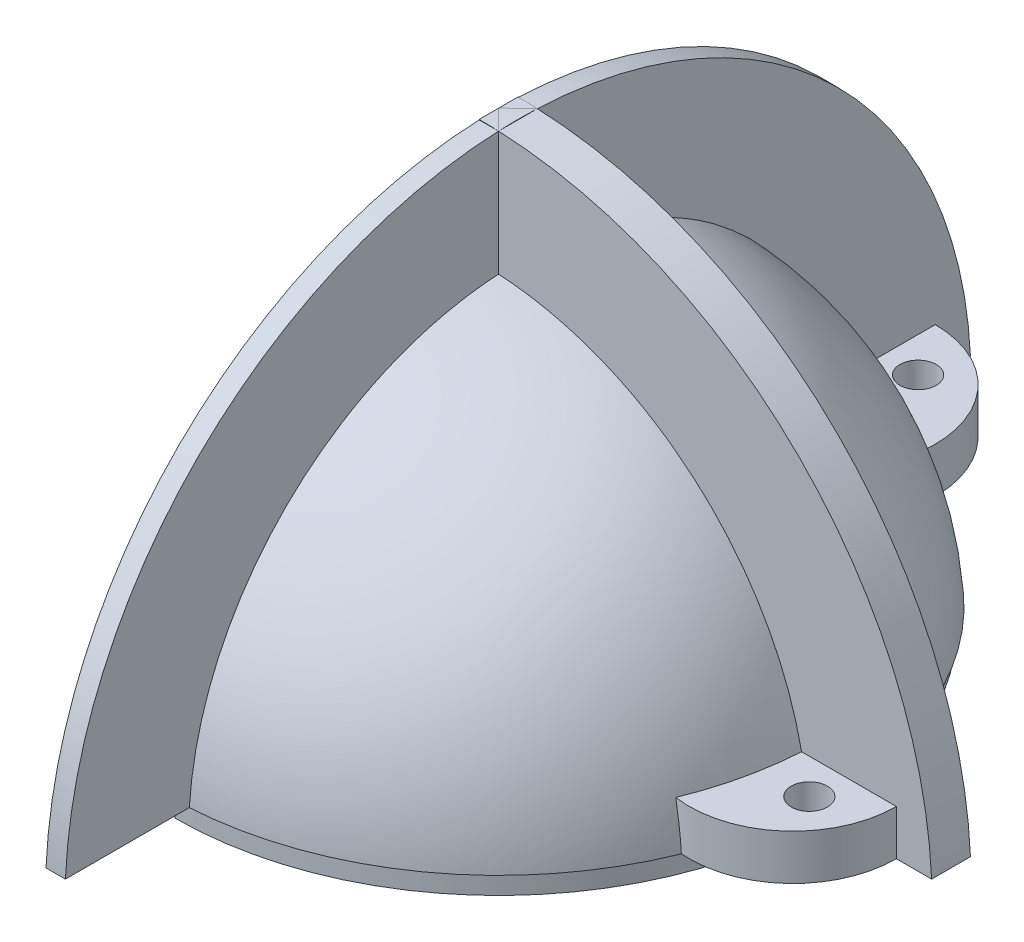
from build123d import *

# Parameters (mm, degrees)
BOSS_EXTRUDE1_DEPTH      = 1.5
BOSS_EXTRUDE1_DEPTH_BACK = 1.5
BOSS_EXTRUDE2_DEPTH      = 1.5
BOSS_EXTRUDE2_DEPTH_BACK = 1.5
SKETCH4_W                = 11.052180397
SKETCH4_H                = 1.65
SKETCH5_R                = 1.4
BOSS_EXTRUDE20_DEPTH     = 3.5
SKETCH6_R                = 26
SKETCH6_R_2              = 25
CUT_EXTRUDE1_DEPTH       = 1.65


with BuildPart() as part:
    # Sketch1 → Revolve1 (revolve)
    with BuildSketch(Plane.XY, mode=Mode.PRIVATE) as revolve1_sk:
        with BuildLine():
            Line((-20.885, 0), (-20.885, 11.793939121))
            ThreePointArc((-20.885, 11.793939121), (-12.091372858, 20.714220415), (0, 23.985))
            Line((0, 23.985), (0, 25.485))
            ThreePointArc((0, 25.485), (-18.020616319, 18.020616319), (-25.485, 0))
            Line((-25.485, 0), (-24.285, 0))
            Line((-24.285, 0), (-24.285, 0.5))
            Line((-24.285, 0.5), (-22.085, 0.5))
            Line((-22.085, 0.5), (-22.085, 0))
            Line((-22.085, 0), (-20.885, 0))
        make_face()
    revolve(revolve1_sk.sketch.rotate(Axis((0, 0, 0), (0, 1, 0)), 270), axis=Axis((0, 0, 0), (0, 1, 0)))



with BuildPart() as body_2:
    # Sketch2 → Boss-Extrude1 (new, two sides)
    with BuildSketch(Plane.XY) as boss_extrude1_sk:
        with BuildLine():
            Line((-24.9, 0), (-35, 0))
            ThreePointArc((-35, 0), (0, 35), (35, 0))
            Line((35, 0), (24.9, 0))
            ThreePointArc((24.9, 0), (0, 24.9), (-24.9, 0))
        make_face()
    extrude(amount=BOSS_EXTRUDE1_DEPTH)
    extrude(boss_extrude1_sk.sketch, amount=-BOSS_EXTRUDE1_DEPTH_BACK)

    # Sketch3 → Boss-Extrude2 (add, two sides)
    with BuildSketch(Plane(origin=(0, 0, 0), x_dir=(0, 0, -1), z_dir=(1, 0, 0))) as boss_extrude2_sk:
        with BuildLine():
            Line((35, 0), (24.9, 0))
            ThreePointArc((24.9, 0), (0, 24.9), (-24.9, 0))
            Line((-24.9, 0), (-35, 0))
            ThreePointArc((-35, 0), (0, 35), (35, 0))
        make_face()
    extrude(amount=BOSS_EXTRUDE2_DEPTH)
    extrude(boss_extrude2_sk.sketch, amount=-BOSS_EXTRUDE2_DEPTH_BACK)

    # Sketch4 → Cut-Revolve2 (revolve, cut)
    with BuildSketch(Plane.XY):
        with Locations((-30.371361379, 0.825)):
            Rectangle(SKETCH4_W, SKETCH4_H)
    revolve(axis=Axis((0, 0, 0), (0, 1, 0)), mode=Mode.SUBTRACT)


with BuildPart() as part_1:
    add(part.part)

    add(body_2.part)  # Boss-Extrude20 merges body 2
    # Sketch5 → Boss-Extrude20 (add)
    with BuildSketch(Plane.XZ.offset(-1.65)):
        with BuildLine():
            Line((-32.23863084, -1.5), (-24.23863084, -1.5))
            ThreePointArc((-24.23863084, -1.5), (-23.660511509, -5.471875377), (-22.4360777, -9.294280094))
            ThreePointArc((-22.4360777, -9.294280094), (-27.026694315, -8.998446643), (-30.695451754, -6.223289498))
            ThreePointArc((-30.695451754, -6.223289498), (-31.843056108, -3.984495189), (-32.23863084, -1.5))
        make_face()
        with Locations(Location((-28.212839525, -4.2, 0), (0, 0, 270))):
            Circle(SKETCH5_R, mode=Mode.SUBTRACT)
        with BuildLine():
            Line((24.23863084, 1.5), (32.23863084, 1.5))
            ThreePointArc((32.23863084, 1.5), (31.843056108, 3.984495189), (30.695451754, 6.223289498))
            ThreePointArc((30.695451754, 6.223289498), (27.026694315, 8.998446643), (22.4360777, 9.294280094))
            ThreePointArc((22.4360777, 9.294280094), (23.660511509, 5.471875377), (24.23863084, 1.5))
        make_face()
        with Locations(Location((28.212839525, 4.2, 0), (0, 0, 270))):
            Circle(SKETCH5_R, mode=Mode.SUBTRACT)
        with BuildLine():
            Line((-1.5, 32.23863084), (-1.5, 24.23863084))
            ThreePointArc((-1.5, 24.23863084), (-5.471875377, 23.660511509), (-9.294280094, 22.4360777))
            ThreePointArc((-9.294280094, 22.4360777), (-8.998446643, 27.026694315), (-6.223289498, 30.695451754))
            ThreePointArc((-6.223289498, 30.695451754), (-3.984495189, 31.843056108), (-1.5, 32.23863084))
        make_face()
        with Locations(Location((-4.2, 28.212839525, 0), (0, 0, 270))):
            Circle(SKETCH5_R, mode=Mode.SUBTRACT)
        with BuildLine():
            Line((1.5, -32.23863084), (1.5, -24.23863084))
            ThreePointArc((1.5, -24.23863084), (5.471875377, -23.660511509), (9.294280094, -22.4360777))
            ThreePointArc((9.294280094, -22.4360777), (8.998446643, -27.026694315), (6.223289498, -30.695451754))
            ThreePointArc((6.223289498, -30.695451754), (3.984495189, -31.843056108), (1.5, -32.23863084))
        make_face()
        with Locations(Location((4.2, -28.212839525, 0), (0, 0, 270))):
            Circle(SKETCH5_R, mode=Mode.SUBTRACT)
    extrude(amount=-BOSS_EXTRUDE20_DEPTH)

    # Sketch6 → Cut-Extrude1 (cut)
    with BuildSketch(Plane.XZ):
        Circle(SKETCH6_R)
        with Locations(Location((0, 0, 0), (0, 0, 270))):
            Circle(SKETCH6_R_2, mode=Mode.SUBTRACT)
    extrude(amount=-CUT_EXTRUDE1_DEPTH, mode=Mode.SUBTRACT)

    # SurfaceCut1
    split(bisect_by=Plane(origin=(0, 0, 0), x_dir=(0, 0, -1), z_dir=(1, 0, 0)), keep=Keep.TOP)


solid = part_1.part
